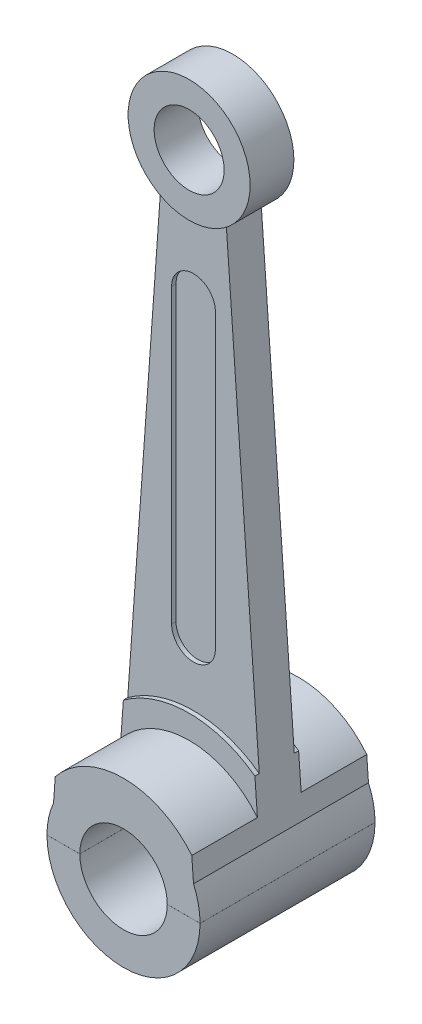
from build123d import *

# Parameters (mm, degrees)
SKETCH1_R                = 1.395
SKETCH1_R_2              = 0.8
BOSS_EXTRUDE1_DEPTH      = 0.5
SKETCH1_R_3              = 2.538
SKETCH1_R_4              = 1
BOSS_EXTRUDE1_2_DEPTH    = 0.5
BOSS_EXTRUDE2_DEPTH      = 0.4
BOSS_EXTRUDE3_DEPTH      = 0.3
BOSS_EXTRUDE4_DEPTH      = 1.5
BOSS_EXTRUDE4_DEPTH_BACK = 2.5
SKETCH2_R                = 2
SKETCH2_R_2              = 1
CUT_EXTRUDE1_DEPTH       = 7.1
SKETCH4_W                = 9.895137424
SKETCH4_H                = 0.001
CUT_EXTRUDE4_DEPTH       = 10.91


with BuildPart() as part:
    # Sketch1 → Boss-Extrude1 (new, symmetric)
    with BuildSketch(Plane.XY):
        with Locations((0, 13.69)):
            Circle(SKETCH1_R)
        with Locations((0, 13.69)):
            Circle(SKETCH1_R_2, mode=Mode.SUBTRACT)
    extrude(amount=BOSS_EXTRUDE1_DEPTH, both=True)



with BuildPart() as body_2:
    # Sketch1 → Boss-Extrude1 2 (new, symmetric)
    with BuildSketch(Plane.XY):
        Circle(SKETCH1_R_3)
        Circle(SKETCH1_R_4, mode=Mode.SUBTRACT)
    extrude(amount=BOSS_EXTRUDE1_2_DEPTH, both=True)


with BuildPart() as part_1:
    add(part.part)

    add(body_2.part)  # Boss-Extrude2 merges body 2
    # Sketch1_3 → Boss-Extrude2 (add, symmetric)
    with BuildSketch(Plane.XY):
        with BuildLine():
            ThreePointArc((0.75, 12.513766605), (0, 12.295), (-0.75, 12.513766605))
            Line((-0.75, 12.513766605), (-1.65, 1.928456378))
            ThreePointArc((-1.65, 1.928456378), (0, 2.538), (1.65, 1.928456378))
            Line((1.65, 1.928456378), (0.75, 12.513766605))
        make_face()
        with BuildLine():
            ThreePointArc((-0.5, 10.69), (0, 11.19), (0.5, 10.69))
            Line((0.5, 10.69), (0.5, 4))
            ThreePointArc((0.5, 4), (0, 3.5), (-0.5, 4))
            Line((-0.5, 4), (-0.5, 10.69))
        make_face(mode=Mode.SUBTRACT)
    extrude(amount=BOSS_EXTRUDE2_DEPTH, both=True)

    # Sketch1_4 → Boss-Extrude3 (add, symmetric)
    with BuildSketch(Plane.XY):
        with BuildLine():
            Line((0.5, 4), (0.5, 10.69))
            ThreePointArc((0.5, 10.69), (0, 11.19), (-0.5, 10.69))
            Line((-0.5, 10.69), (-0.5, 4))
            ThreePointArc((-0.5, 4), (0, 3.5), (0.5, 4))
        make_face()
    extrude(amount=BOSS_EXTRUDE3_DEPTH, both=True)

    # Sketch2 → Boss-Extrude4 (add, two sides: drawn at the far end of the back side and taken through both)
    with BuildSketch(Plane.XY.offset(0.5).offset(-BOSS_EXTRUDE4_DEPTH_BACK)):
        Circle(SKETCH2_R)
        Circle(SKETCH2_R_2, mode=Mode.SUBTRACT)
    extrude(amount=BOSS_EXTRUDE4_DEPTH + BOSS_EXTRUDE4_DEPTH_BACK)

    # Sketch3 → Cut-Extrude1 (cut, symmetric)
    with BuildSketch(Plane.XY):
        with BuildLine():
            Line((-0.75, 12.513766605), (-2.890594353, 1.97343971))
            ThreePointArc((-2.890594353, 1.97343971), (0, -3.5), (2.890594353, 1.97343971))
            Line((2.890594353, 1.97343971), (0.75, 12.513766605))
            Line((0.75, 12.513766605), (1.6, 0.708872344))
            ThreePointArc((1.6, 0.708872344), (0, -1.75), (-1.6, 0.708872344))
            Line((-1.6, 0.708872344), (-0.75, 12.513766605))
        make_face()
    extrude(amount=CUT_EXTRUDE1_DEPTH, both=True, mode=Mode.SUBTRACT)

    # Sketch4 → Cut-Extrude4 (cut, symmetric)
    with BuildSketch(Plane.XY):
        with Locations((0.269871194, 0.0005)):
            Rectangle(SKETCH4_W, SKETCH4_H)
    extrude(amount=CUT_EXTRUDE4_DEPTH, both=True, mode=Mode.SUBTRACT)


with BuildPart() as cut_extrude4_piece_1:
    # of the separate pieces the step leaves, piece 1, a body of its own (cut_extrude4_pieces)
    add(part_1.part.solids().sort_by_distance((1.50383015, 2.044489882, -0.5))[0])


with BuildPart() as cut_extrude4_piece_2:
    # of the separate pieces the step leaves, piece 2, a body of its own (cut_extrude4_pieces)
    add(part_1.part.solids().sort_by_distance((-1.75, 0, -2))[0])


solid = Compound([cut_extrude4_piece_1.part, cut_extrude4_piece_2.part])
